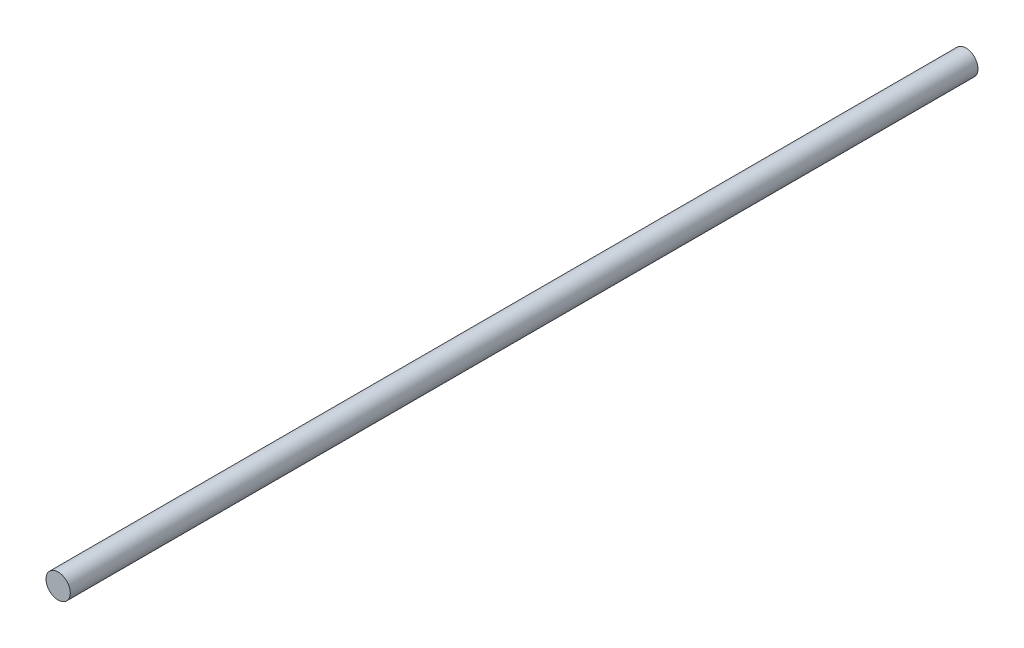
from build123d import *

# Parameters (mm, degrees)
SKETCH1_R           = 1.5
BOSS_EXTRUDE1_DEPTH = 112


with BuildPart() as part:
    # Sketch1 → Boss-Extrude1 (new body)
    with BuildSketch(Plane.XY):
        Circle(SKETCH1_R)
    extrude(amount=BOSS_EXTRUDE1_DEPTH)


solid = part.part
